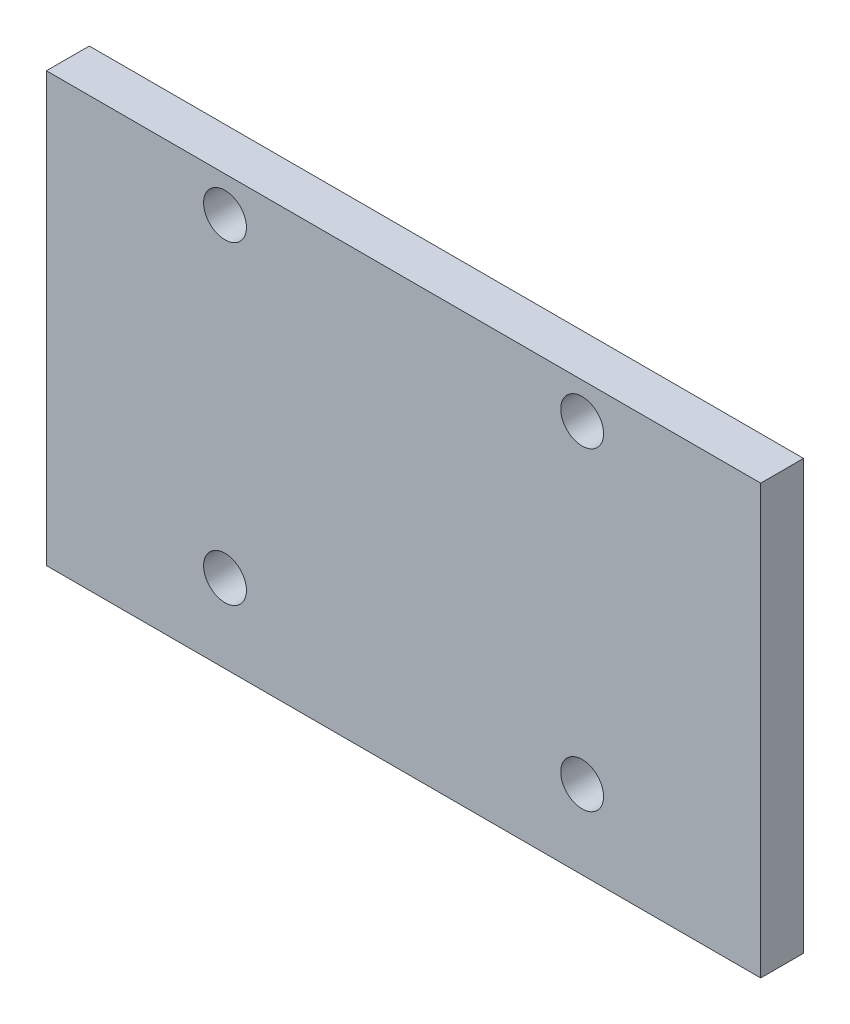
from build123d import *

# Parameters (mm, degrees)
ESQUISSE1_W        = 50
ESQUISSE1_H        = 30
ESQUISSE1_R        = 1.5
BOSS_EXTRU_1_DEPTH = 3


with BuildPart() as part:
    # Esquisse1 → Boss.-Extru.1 (new body)
    with BuildSketch(Plane.XY):
        with Locations((-5.860215054, 0.564245437)):
            Rectangle(ESQUISSE1_W, ESQUISSE1_H)
        with Locations((-18.360215054, 13.064245437)):
            Circle(ESQUISSE1_R, mode=Mode.SUBTRACT)
        with Locations((6.639784946, 13.064245437)):
            Circle(ESQUISSE1_R, mode=Mode.SUBTRACT)
        with Locations((-18.360215054, -8.935754563)):
            Circle(ESQUISSE1_R, mode=Mode.SUBTRACT)
        with Locations((6.639784946, -8.935754563)):
            Circle(ESQUISSE1_R, mode=Mode.SUBTRACT)
    extrude(amount=BOSS_EXTRU_1_DEPTH)


solid = part.part
